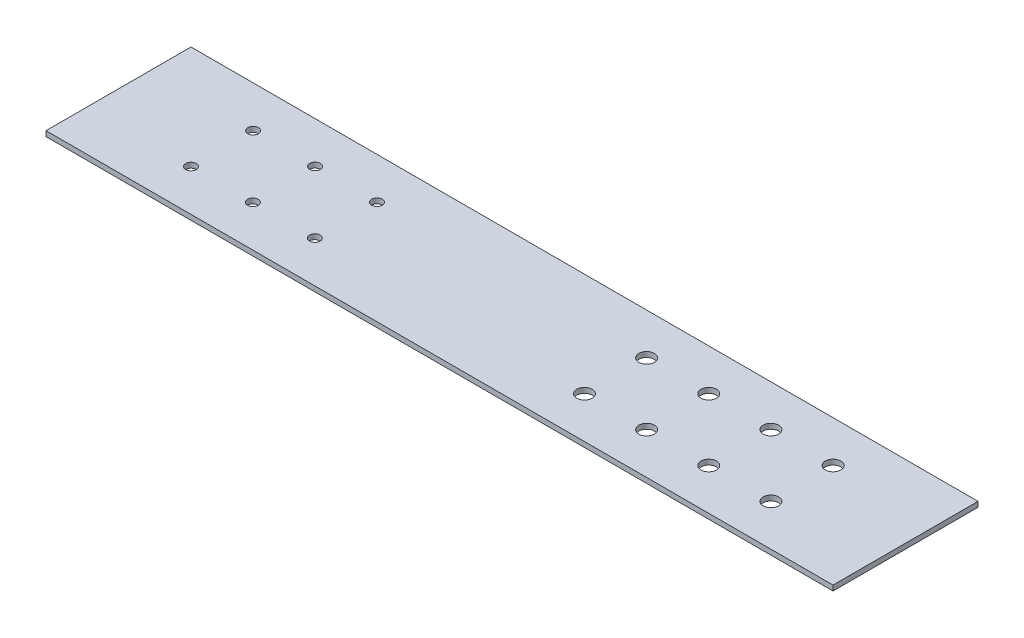
from build123d import *

# Parameters (mm, degrees)
SKETCH1_W           = 482.6
SKETCH1_H           = 88.9
BOSS_EXTRUDE1_DEPTH = 3.175
SKETCH2_R           = 3.25
SKETCH2_R_2         = 4.7625
CUT_EXTRUDE1_DEPTH  = 3.175


with BuildPart() as part:
    # Sketch1 → Boss-Extrude1 (new body)
    with BuildSketch(Plane(origin=(0, 0, 0), x_dir=(1, 0, 0), z_dir=(0, 1, 0))):
        Rectangle(SKETCH1_W, SKETCH1_H)
    extrude(amount=BOSS_EXTRUDE1_DEPTH)

    # Sketch2 → Cut-Extrude1 (cut)
    with BuildSketch(Plane(origin=(0, 3.175, 0), x_dir=(1, 0, 0), z_dir=(0, 1, 0))):
        with Locations((-101.842969122, -19.05)):
            Circle(SKETCH2_R)
        with Locations((-139.821484561, -19.05)):
            Circle(SKETCH2_R)
        with Locations((-177.8, -19.05)):
            Circle(SKETCH2_R)
        with Locations((-139.821484561, 19.05)):
            Circle(SKETCH2_R)
        with Locations((-177.8, 19.05)):
            Circle(SKETCH2_R)
        with Locations((-101.842969122, 19.05)):
            Circle(SKETCH2_R)
        with Locations((177.8, -19.05)):
            Circle(SKETCH2_R_2)
        with Locations((139.7, -19.05)):
            Circle(SKETCH2_R_2)
        with Locations((101.6, -19.05)):
            Circle(SKETCH2_R_2)
        with Locations((63.5, -19.05)):
            Circle(SKETCH2_R_2)
        with Locations((139.7, 19.05)):
            Circle(SKETCH2_R_2)
        with Locations((101.6, 19.05)):
            Circle(SKETCH2_R_2)
        with Locations((63.5, 19.05)):
            Circle(SKETCH2_R_2)
        with Locations((177.8, 19.05)):
            Circle(SKETCH2_R_2)
    extrude(amount=-CUT_EXTRUDE1_DEPTH, mode=Mode.SUBTRACT)


solid = part.part
